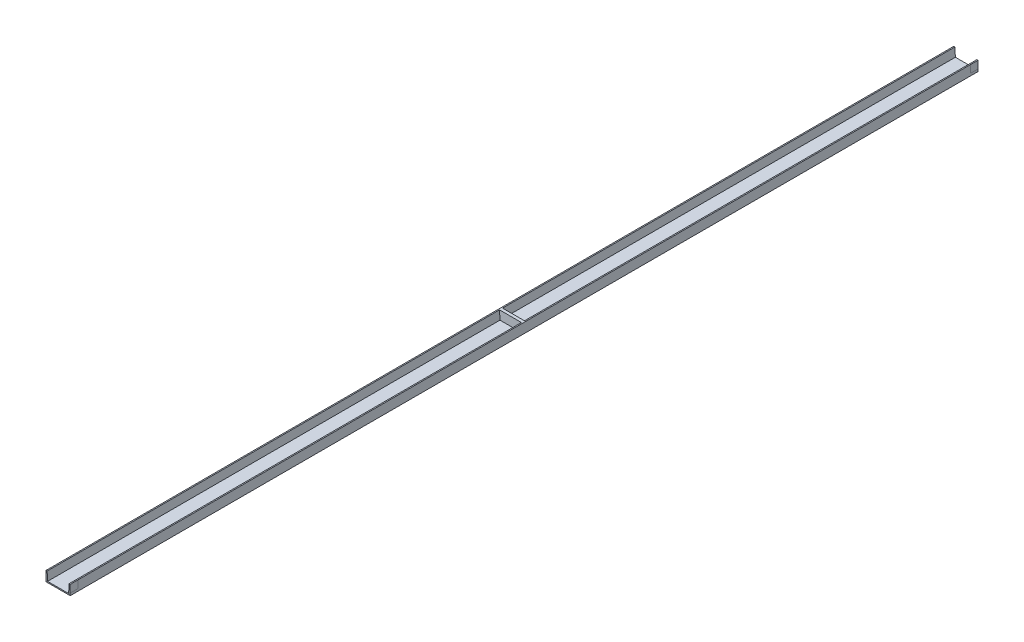
from build123d import *

# Parameters (mm, degrees)
AUFSATZ_LINEAR_AUSTRAGEN1_DEPTH = 3000
AUFSATZ_LINEAR_AUSTRAGEN2_DEPTH = 10


with BuildPart() as part:
    # Skizze1 → Aufsatz-Linear austragen1 (new body, symmetric)
    with BuildSketch(Plane.XY):
        Polygon((80, 0), (-80, 0), (-80, 65), (-72.5, 65), (-69.5, 7.5), (69.5, 7.5), (72.5, 65), (80, 65), align=None)
    extrude(amount=AUFSATZ_LINEAR_AUSTRAGEN1_DEPTH, both=True)

    # Skizze2 → Aufsatz-Linear austragen2 (add, symmetric)
    with BuildSketch(Plane.XY):
        Polygon((-69.5, 7.5), (-72.5, 65), (72.5, 65), (69.5, 7.5), align=None)
    extrude(amount=AUFSATZ_LINEAR_AUSTRAGEN2_DEPTH, both=True)


solid = part.part
